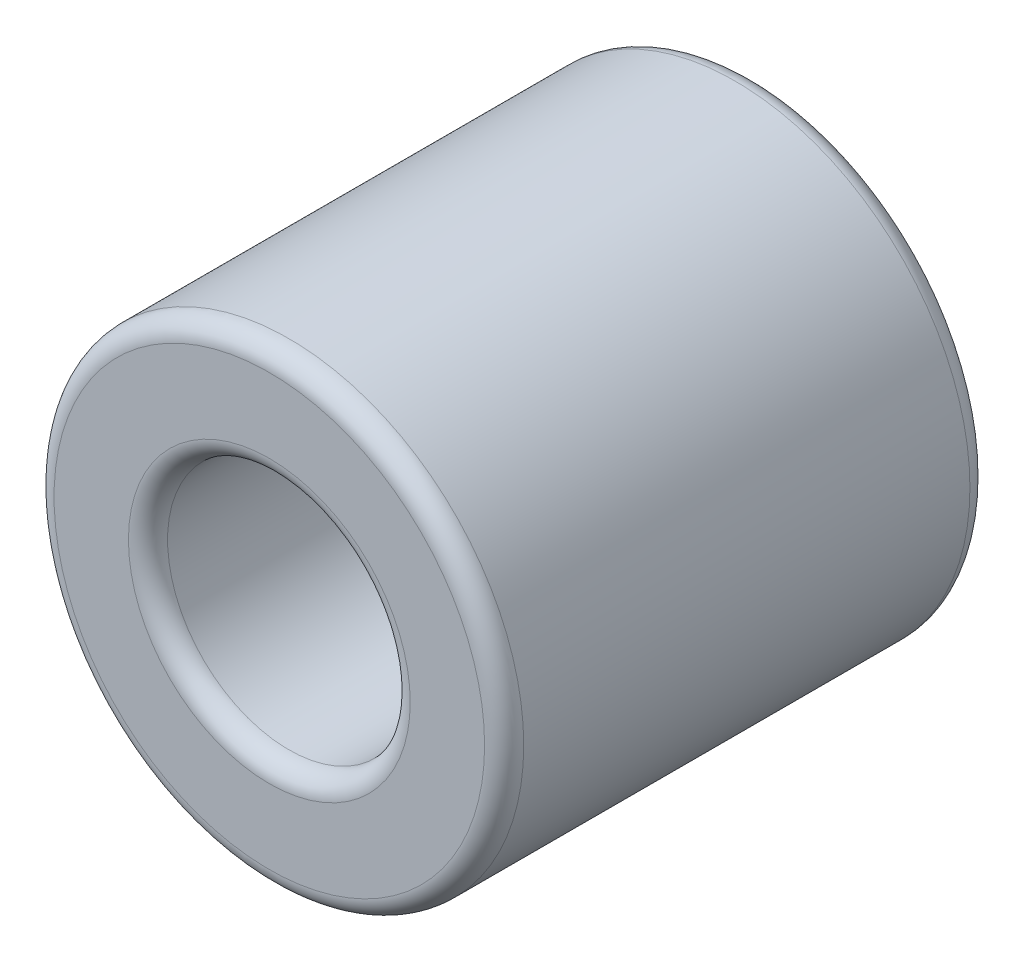
from build123d import *

# Parameters (mm, degrees)
SKICA2_R                = 3
SKICA2_R_2              = 1.55
P_IDAT_VYSUNUT_M1_DEPTH = 6.2
ZAOBLIT1_R              = 0.25


with BuildPart() as part:
    # Skica2 → Přidat vysunutím1 (new body)
    with BuildSketch(Plane.XY):
        Circle(SKICA2_R)
        Circle(SKICA2_R_2, mode=Mode.SUBTRACT)
    extrude(amount=P_IDAT_VYSUNUT_M1_DEPTH)

    # Zaoblit1
    zaoblit1_edges = [part.edges().sort_by_distance(p)[0] for p in [
        (-3, 0, 0),
        (-3, 0, 6.2),
        (-1.55, 0, 0),
        (-1.55, 0, 6.2),
    ]]
    fillet(zaoblit1_edges, radius=ZAOBLIT1_R)


solid = part.part
